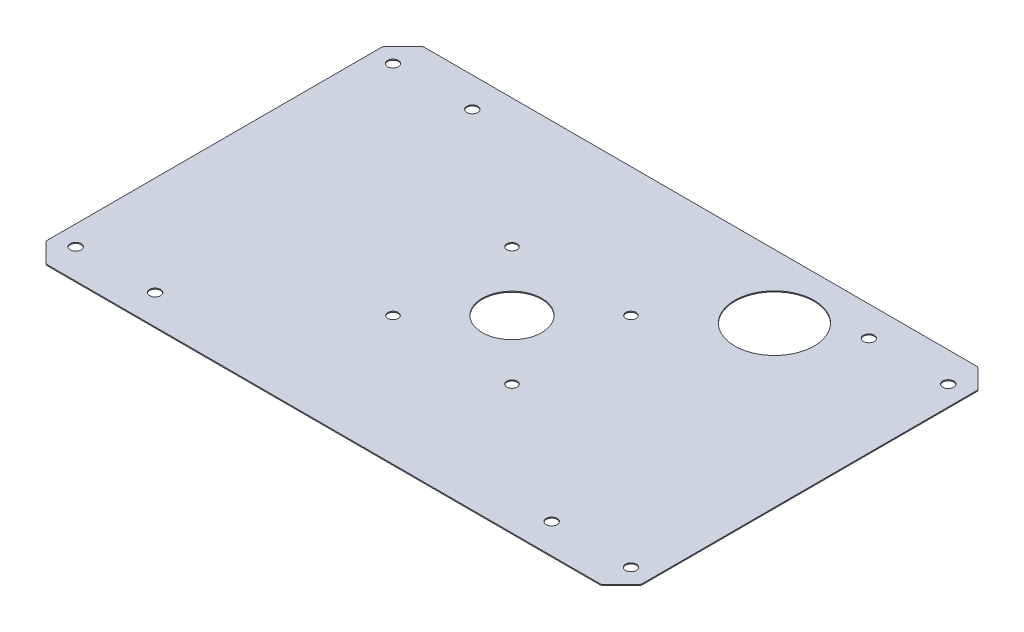
from build123d import *

# Parameters (mm, degrees)
ESQUISSE1_W                     = 300
ESQUISSE1_H                     = 190
BOSS_EXTRU_1_DEPTH              = 0.5
CHANFREIN1_SIZE                 = 10
CONG_1_R                        = 2
ESQUISSE2_R                     = 2.75
ENL_V_MAT_EXTRU_1_DEPTH         = 1.5
R_P_TITION_LIN_AIRE1_COUNT      = 2
R_P_TITION_LIN_AIRE1_PITCH      = 240
R_P_TITION_LIN_AIRE1_COUNT_DIR2 = 2
R_P_TITION_LIN_AIRE1_PITCH_DIR2 = 160
ESQUISSE4_R                     = 2.75
ESQUISSE4_R_2                   = 20
ESQUISSE4_R_3                   = 15
ENL_V_MAT_EXTRU_3_DEPTH         = 10
ESQUISSE5_R                     = 2.6
ENL_V_MAT_EXTRU_4_DEPTH         = 1.5


with BuildPart() as part:
    # Esquisse1 → Boss.-Extru.1 (new body)
    with BuildSketch(Plane(origin=(0, 0, 0), x_dir=(1, 0, 0), z_dir=(0, 1, 0))):
        Rectangle(ESQUISSE1_W, ESQUISSE1_H)
    extrude(amount=BOSS_EXTRU_1_DEPTH)

    # Chanfrein1
    chanfrein1_edges = [part.edges().sort_by_distance(p)[0] for p in [
        (150, 0.25, 95),
        (-150, 0.25, 95),
        (-150, 0.25, -95),
        (150, 0.25, -95),
    ]]
    chamfer(chanfrein1_edges, length=CHANFREIN1_SIZE)

    # Congé1
    cong_1_edges = [part.edges().sort_by_distance(p)[0] for p in [
        (140, 0.25, 95),
        (-140, 0.25, 95),
        (-150, 0.25, -85),
        (-150, 0.25, 85),
        (150, 0.25, -85),
        (150, 0.25, 85),
        (-140, 0.25, -95),
        (140, 0.25, -95),
    ]]
    fillet(cong_1_edges, radius=CONG_1_R)

    # Esquisse2 → Enlèv. mat.-Extru.1 (cut, through all)
    with BuildSketch(Plane.XZ):
        with Locations((-140, 80)):
            Circle(ESQUISSE2_R)
        with Locations((-100, 80)):
            Circle(ESQUISSE2_R)
    enl_v_mat_extru_1 = extrude(amount=-ENL_V_MAT_EXTRU_1_DEPTH, mode=Mode.SUBTRACT)

    # Répétition linéaire1: Enl_v. mat.-Extru.1 2 × 2
    with Locations(*[(i * R_P_TITION_LIN_AIRE1_PITCH, 0, -j * R_P_TITION_LIN_AIRE1_PITCH_DIR2) for i in range(R_P_TITION_LIN_AIRE1_COUNT) for j in range(R_P_TITION_LIN_AIRE1_COUNT_DIR2) if (i, j) != (0, 0)]):
        add(enl_v_mat_extru_1, mode=Mode.SUBTRACT)

    # Esquisse4 → Enlèv. mat.-Extru.3 (cut)
    with BuildSketch(Plane(origin=(0, 0.5, 0), x_dir=(1, 0, 0), z_dir=(0, 1, 0))):
        with Locations((100, 80)):
            Circle(ESQUISSE4_R)
        with Locations((69.55, 62.8)):
            Circle(ESQUISSE4_R_2)
        Circle(ESQUISSE4_R_3)
    extrude(amount=-ENL_V_MAT_EXTRU_3_DEPTH, mode=Mode.SUBTRACT)

    # Esquisse5 → Enlèv. mat.-Extru.4 (cut, through all)
    with BuildSketch(Plane(origin=(0, 0.5, 0), x_dir=(1, 0, 0), z_dir=(0, 1, 0))):
        with Locations((-30, 30)):
            Circle(ESQUISSE5_R)
        with Locations((30, 30)):
            Circle(ESQUISSE5_R)
        with Locations((30, -30)):
            Circle(ESQUISSE5_R)
        with Locations((-30, -30)):
            Circle(ESQUISSE5_R)
    extrude(amount=-ENL_V_MAT_EXTRU_4_DEPTH, mode=Mode.SUBTRACT)


solid = part.part
